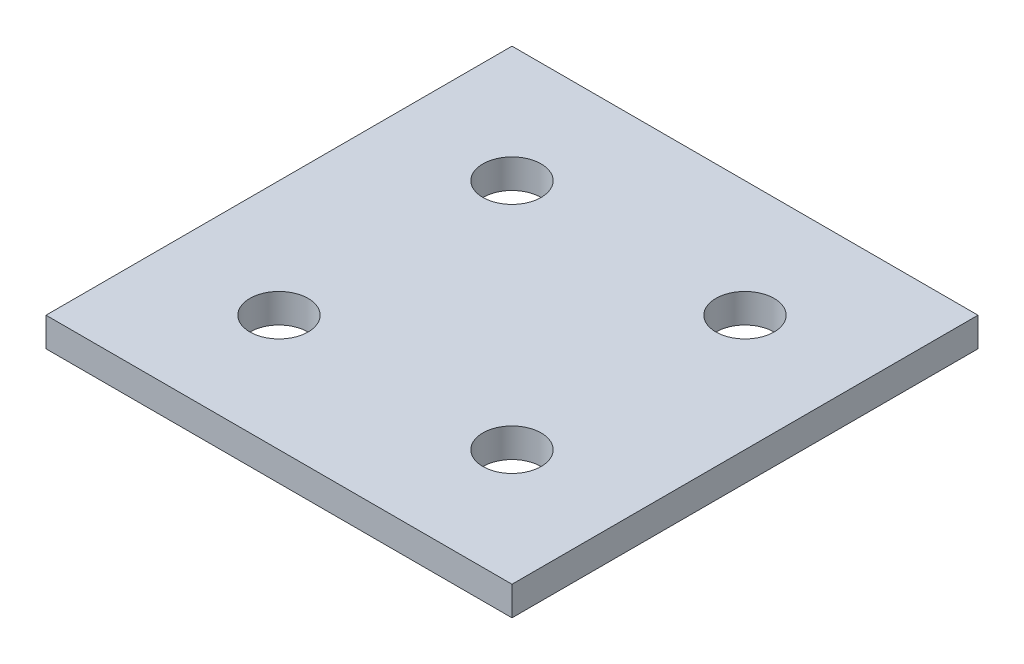
from build123d import *

# Parameters (mm, degrees)
SKETCH1_W                  = 101.6
SKETCH1_H                  = 101.6
BOSS_EXTRUDE1_DEPTH        = 6.35
F_1_2_0_5000_DOWEL_HOLE1_D = 12.7


with BuildPart() as part:
    # Sketch1 → Boss-Extrude1 (new body)
    with BuildSketch(Plane(origin=(0, 0, 0), x_dir=(1, 0, 0), z_dir=(0, 1, 0))):
        with Locations((50.8, 50.8)):
            Rectangle(SKETCH1_W, SKETCH1_H)
    extrude(amount=BOSS_EXTRUDE1_DEPTH)

    # 1/2 (0.5000) Dowel Hole1 (through all)
    with Locations(Plane(origin=(25.4, 6.35, -25.4), x_dir=(0, 0, 1), z_dir=(0, 1, 0))):
        with Locations((0, 0), (-50.8, 0), (-50.8, 50.8), (0, 50.8)):
            Hole(F_1_2_0_5000_DOWEL_HOLE1_D / 2)


solid = part.part
